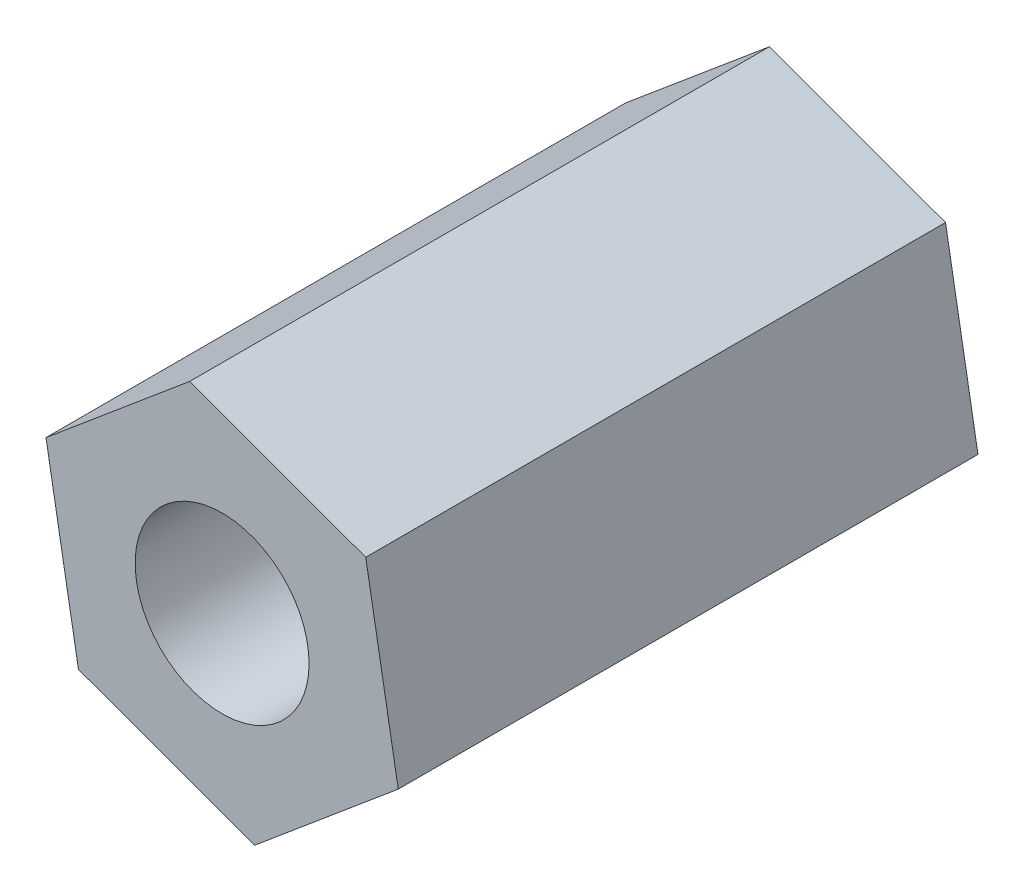
from build123d import *

# Parameters (mm, degrees)
SKETCH_1_R      = 1.5
EXTRUDE_1_DEPTH = 10


with BuildPart() as part:
    # 草图1 → 凸台-拉伸1 (new body)
    with BuildSketch(Plane.XY):
        Polygon((-129.741556691, -57.086424359), (-127.263938912, -55.009228299), (-127.824034578, -51.824950331), (-130.861748025, -50.717868423), (-133.339365804, -52.795064483), (-132.779270137, -55.979342451), align=None)
        with Locations((-130.301652358, -53.902146391)):
            Circle(SKETCH_1_R, mode=Mode.SUBTRACT)
    extrude(amount=EXTRUDE_1_DEPTH)


solid = part.part
